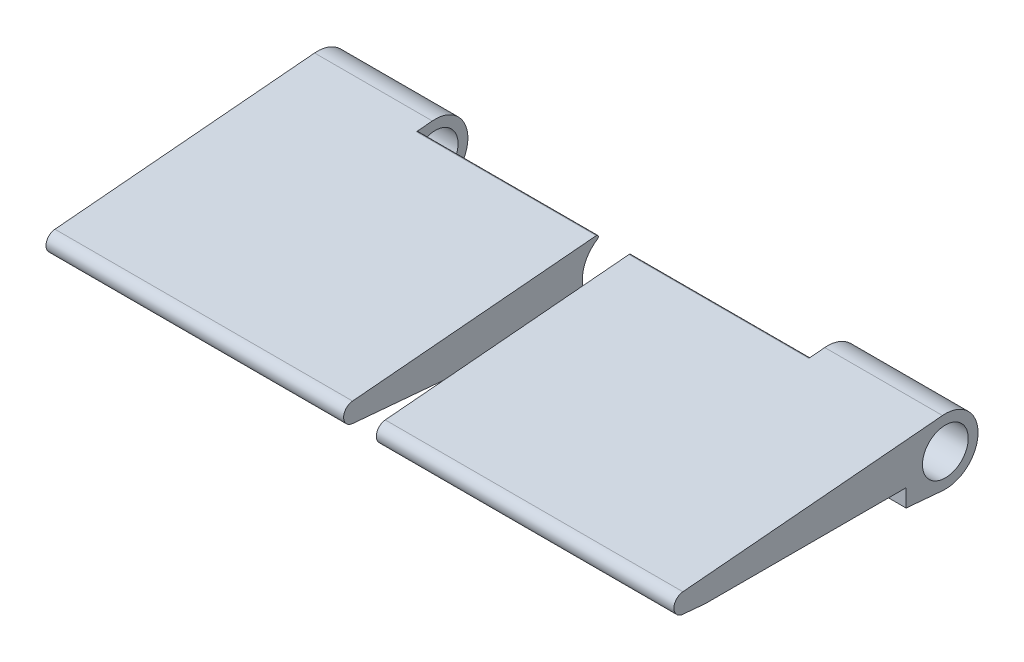
from build123d import *

# Parameters (mm, degrees)
BOSS_EXTRUDE1_DEPTH = 27.5
BOSS_EXTRUDE2_START = -18
SKETCH1_3_R         = 3.5
BOSS_EXTRUDE2_DEPTH = 18
FILLET1_R           = 0.3
CUT_EXTRUDE1_START  = 6
SKETCH2_W           = 18
SKETCH2_H           = 4.33028374
CUT_EXTRUDE1_DEPTH  = 48


with BuildPart() as part:
    # Sketch1 → Boss-Extrude1 (new body)
    with BuildSketch(Plane(origin=(0, 0, 0), x_dir=(0, 0, -1), z_dir=(1, 0, 0))):
        with BuildLine():
            Line((-0.4375, 4.980822598), (-40.13125, 1.494246779))
            ThreePointArc((-40.13125, 1.494246779), (-41.5, 0), (-40.13125, -1.494246779))
            Line((-40.13125, -1.494246779), (-0.4375, -4.980822598))
            ThreePointArc((-0.4375, -4.980822598), (-5, 0), (-0.4375, 4.980822598))
        make_face()
    extrude(amount=BOSS_EXTRUDE1_DEPTH)

    # Sketch1_3 → Boss-Extrude2 (add)
    with BuildSketch(Plane(origin=(0, 0, 0), x_dir=(0, 0, -1), z_dir=(1, 0, 0)).offset(BOSS_EXTRUDE2_START)):
        with BuildLine():
            Line((-0.4375, 4.980822598), (-40.13125, 1.494246779))
            ThreePointArc((-40.13125, 1.494246779), (-41.5, 0), (-40.13125, -1.494246779))
            Line((-40.13125, -1.494246779), (-0.4375, -4.980822598))
            ThreePointArc((-0.4375, -4.980822598), (5, 0), (-0.4375, 4.980822598))
        make_face()
        Circle(SKETCH1_3_R, mode=Mode.SUBTRACT)
    extrude(amount=BOSS_EXTRUDE2_DEPTH)

    # Fillet1
    fillet1_edges = [part.edges().sort_by_distance(p)[0] for p in [
        (13.75, -4.980822598, 0.4375),
        (13.75, 4.980822598, 0.4375),
    ]]
    fillet(fillet1_edges, radius=FILLET1_R)

    # Sketch2 → Cut-Extrude1 (cut)
    with BuildSketch(Plane.XY.offset(CUT_EXTRUDE1_START)):
        with Locations((-9, -3.96514187)):
            Rectangle(SKETCH2_W, SKETCH2_H)
    extrude(amount=CUT_EXTRUDE1_DEPTH, mode=Mode.SUBTRACT)


with BuildPart() as body_2:
    # Mirror2: mirrored copy
    add(part.part.mirror(Plane(origin=(30, 0, 0), x_dir=(0, 0, 1), z_dir=(1, 0, 0))))


solid = Compound([part.part, body_2.part])
